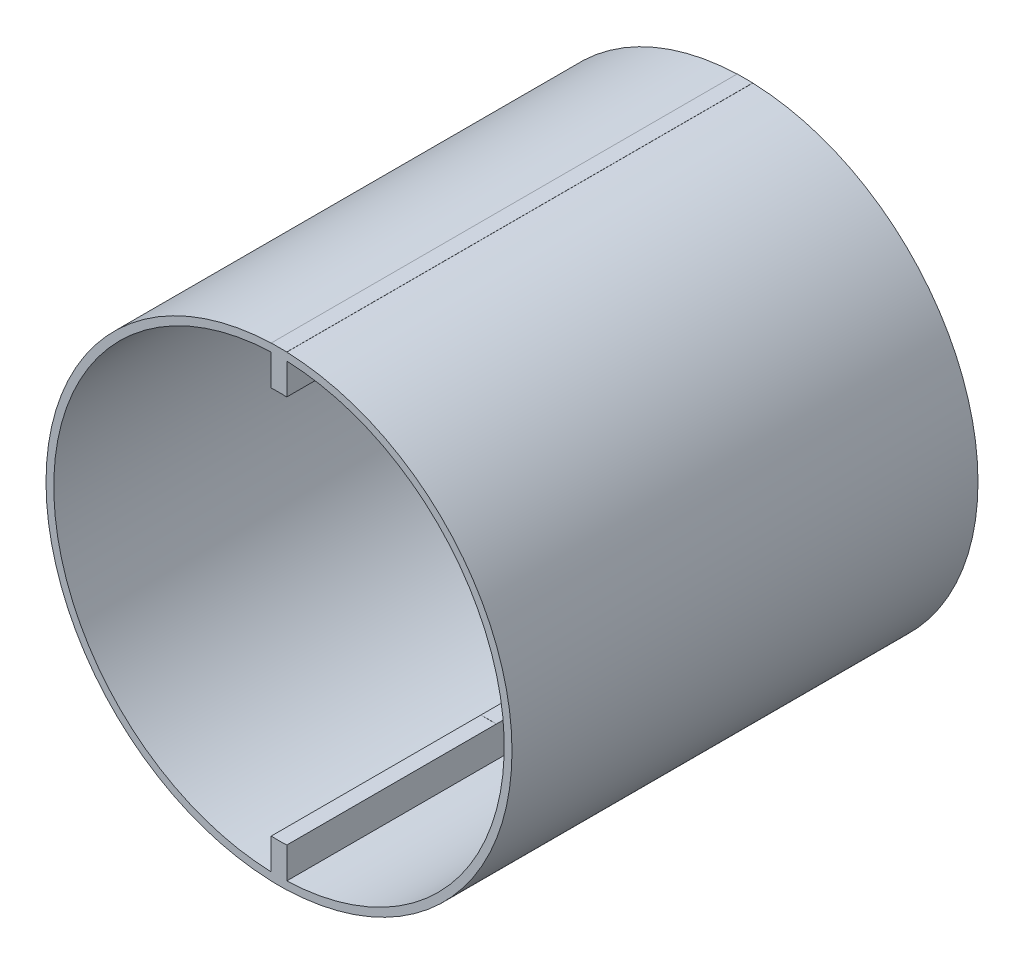
from build123d import *

# Parameters (mm, degrees)
BOSS_EXTRU_1_DEPTH      = 60
ESQUISSE2_R             = 30
ESQUISSE2_R_2           = 29
BOSS_EXTRU_2_DEPTH      = 60
ESQUISSE3_R             = 25
ENL_V_MAT_EXTRU_1_DEPTH = 27
ESQUISSE5_W             = 17
ESQUISSE5_H             = 21.625890028
ENL_V_MAT_EXTRU_2_DEPTH = 8
ESQUISSE6_R             = 2.225
ENL_V_MAT_EXTRU_3_DEPTH = 2


with BuildPart() as part:
    # Esquisse1 → Boss.-Extru.1 (new body)
    with BuildSketch(Plane.XY):
        with BuildLine():
            Line((1, -15.006468588), (1, -3.354101966))
            ThreePointArc((1, -3.354101966), (3.5, 0), (1, 3.354101966))
            Line((1, 3.354101966), (1, 30))
            Line((1, 30), (-1, 30))
            Line((-1, 30), (-1, 3.354101966))
            ThreePointArc((-1, 3.354101966), (-3.5, 0), (-1, -3.354101966))
            Line((-1, -3.354101966), (-1, -30))
            Line((-1, -30), (1, -30))
            Line((1, -30), (1, -15.006468588))
        make_face()
    extrude(amount=BOSS_EXTRU_1_DEPTH)

    # Esquisse2 → Boss.-Extru.2 (add)
    with BuildSketch(Plane.XY.offset(60)):
        Circle(ESQUISSE2_R)
        Circle(ESQUISSE2_R_2, mode=Mode.SUBTRACT)
    extrude(amount=-BOSS_EXTRU_2_DEPTH)

    # Esquisse3 → Enlèv. mat.-Extru.1 (cut)
    with BuildSketch(Plane.XY.offset(60)):
        Circle(ESQUISSE3_R)
    extrude(amount=-ENL_V_MAT_EXTRU_1_DEPTH, mode=Mode.SUBTRACT)

    # Esquisse5 → Enlèv. mat.-Extru.2 (cut)
    with BuildSketch(Plane.ZY.offset(1)):
        with Locations((24.5, -14.16704698)):
            Rectangle(ESQUISSE5_W, ESQUISSE5_H)
        with Locations((24.5, 14.16704698)):
            Rectangle(ESQUISSE5_W, ESQUISSE5_H)
    extrude(amount=-ENL_V_MAT_EXTRU_2_DEPTH, mode=Mode.SUBTRACT)

    # Esquisse6 → Enlèv. mat.-Extru.3 (cut)
    with BuildSketch(Plane.XY.offset(33)):
        Circle(ESQUISSE6_R)
    extrude(amount=-ENL_V_MAT_EXTRU_3_DEPTH, mode=Mode.SUBTRACT)


solid = part.part
